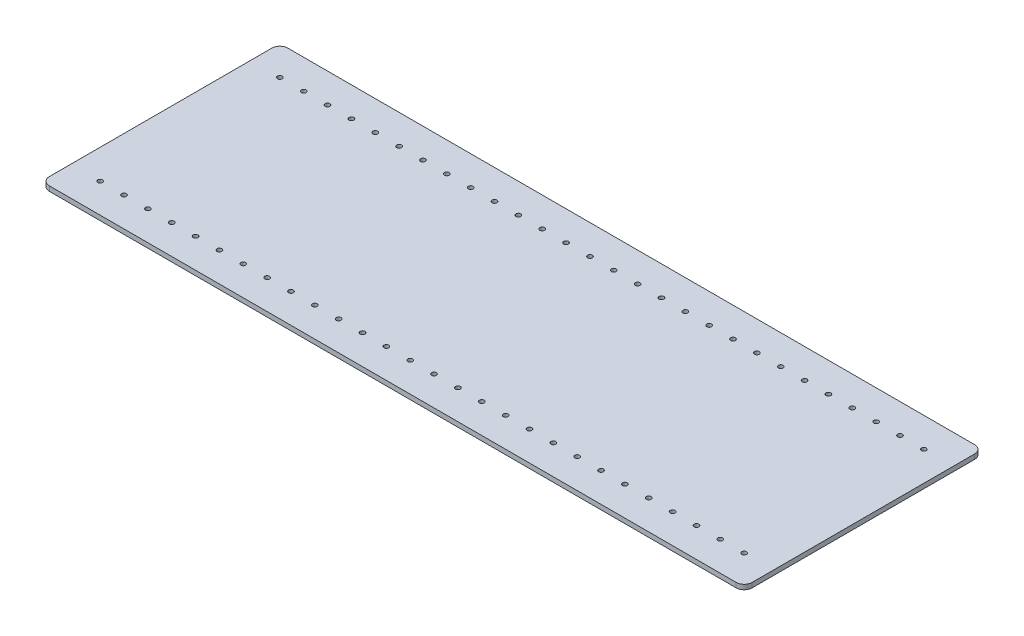
from build123d import *

# Parameters (mm, degrees)
SKETCH2_R           = 1.5
BOSS_EXTRUDE1_DEPTH = 3


with BuildPart() as part:
    # Sketch2 → Boss-Extrude1 (new body)
    with BuildSketch(Plane(origin=(0, 0, 0), x_dir=(1, 0, 0), z_dir=(0, 1, 0))):
        with BuildLine():
            Line((0, 5), (0, 145))
            ThreePointArc((0, 145), (1.464466094, 148.535533906), (5, 150))
            Line((5, 150), (437, 150))
            ThreePointArc((437, 150), (440.535533906, 148.535533906), (442, 145))
            Line((442, 145), (442, 5))
            ThreePointArc((442, 5), (440.535533906, 1.464466094), (437, 0))
            Line((437, 0), (5, 0))
            ThreePointArc((5, 0), (1.464466094, 1.464466094), (0, 5))
        make_face()
        with Locations((18.5, 131.5)):
            Circle(SKETCH2_R, mode=Mode.SUBTRACT)
        with Locations((18.5, 18.5)):
            Circle(SKETCH2_R, mode=Mode.SUBTRACT)
        with Locations((78.5, 18.5)):
            Circle(SKETCH2_R, mode=Mode.SUBTRACT)
        with Locations((63.5, 18.5)):
            Circle(SKETCH2_R, mode=Mode.SUBTRACT)
        with Locations((48.5, 18.5)):
            Circle(SKETCH2_R, mode=Mode.SUBTRACT)
        with Locations((33.5, 18.5)):
            Circle(SKETCH2_R, mode=Mode.SUBTRACT)
        with Locations((78.5, 131.5)):
            Circle(SKETCH2_R, mode=Mode.SUBTRACT)
        with Locations((63.5, 131.5)):
            Circle(SKETCH2_R, mode=Mode.SUBTRACT)
        with Locations((48.5, 131.5)):
            Circle(SKETCH2_R, mode=Mode.SUBTRACT)
        with Locations((33.5, 131.5)):
            Circle(SKETCH2_R, mode=Mode.SUBTRACT)
        with Locations((123.5, 131.5)):
            Circle(SKETCH2_R, mode=Mode.SUBTRACT)
        with Locations((108.5, 131.5)):
            Circle(SKETCH2_R, mode=Mode.SUBTRACT)
        with Locations((93.5, 131.5)):
            Circle(SKETCH2_R, mode=Mode.SUBTRACT)
        with Locations((123.5, 18.5)):
            Circle(SKETCH2_R, mode=Mode.SUBTRACT)
        with Locations((108.5, 18.5)):
            Circle(SKETCH2_R, mode=Mode.SUBTRACT)
        with Locations((93.5, 18.5)):
            Circle(SKETCH2_R, mode=Mode.SUBTRACT)
        with Locations((138.5, 18.5)):
            Circle(SKETCH2_R, mode=Mode.SUBTRACT)
        with Locations((153.5, 131.5)):
            Circle(SKETCH2_R, mode=Mode.SUBTRACT)
        with Locations((138.5, 131.5)):
            Circle(SKETCH2_R, mode=Mode.SUBTRACT)
        with Locations((183.5, 131.5)):
            Circle(SKETCH2_R, mode=Mode.SUBTRACT)
        with Locations((168.5, 131.5)):
            Circle(SKETCH2_R, mode=Mode.SUBTRACT)
        with Locations((183.5, 18.5)):
            Circle(SKETCH2_R, mode=Mode.SUBTRACT)
        with Locations((168.5, 18.5)):
            Circle(SKETCH2_R, mode=Mode.SUBTRACT)
        with Locations((153.5, 18.5)):
            Circle(SKETCH2_R, mode=Mode.SUBTRACT)
        with Locations((198.5, 18.5)):
            Circle(SKETCH2_R, mode=Mode.SUBTRACT)
        with Locations((243.5, 18.5)):
            Circle(SKETCH2_R, mode=Mode.SUBTRACT)
        with Locations((228.5, 18.5)):
            Circle(SKETCH2_R, mode=Mode.SUBTRACT)
        with Locations((213.5, 18.5)):
            Circle(SKETCH2_R, mode=Mode.SUBTRACT)
        with Locations((258.5, 18.5)):
            Circle(SKETCH2_R, mode=Mode.SUBTRACT)
        with Locations((303.5, 18.5)):
            Circle(SKETCH2_R, mode=Mode.SUBTRACT)
        with Locations((288.5, 18.5)):
            Circle(SKETCH2_R, mode=Mode.SUBTRACT)
        with Locations((273.5, 18.5)):
            Circle(SKETCH2_R, mode=Mode.SUBTRACT)
        with Locations((333.5, 18.5)):
            Circle(SKETCH2_R, mode=Mode.SUBTRACT)
        with Locations((318.5, 18.5)):
            Circle(SKETCH2_R, mode=Mode.SUBTRACT)
        with Locations((348.5, 18.5)):
            Circle(SKETCH2_R, mode=Mode.SUBTRACT)
        with Locations((393.5, 18.5)):
            Circle(SKETCH2_R, mode=Mode.SUBTRACT)
        with Locations((378.5, 18.5)):
            Circle(SKETCH2_R, mode=Mode.SUBTRACT)
        with Locations((363.5, 18.5)):
            Circle(SKETCH2_R, mode=Mode.SUBTRACT)
        with Locations((423.5, 18.5)):
            Circle(SKETCH2_R, mode=Mode.SUBTRACT)
        with Locations((408.5, 18.5)):
            Circle(SKETCH2_R, mode=Mode.SUBTRACT)
        with Locations((198.5, 131.5)):
            Circle(SKETCH2_R, mode=Mode.SUBTRACT)
        with Locations((228.5, 131.5)):
            Circle(SKETCH2_R, mode=Mode.SUBTRACT)
        with Locations((213.5, 131.5)):
            Circle(SKETCH2_R, mode=Mode.SUBTRACT)
        with Locations((258.5, 131.5)):
            Circle(SKETCH2_R, mode=Mode.SUBTRACT)
        with Locations((243.5, 131.5)):
            Circle(SKETCH2_R, mode=Mode.SUBTRACT)
        with Locations((288.5, 131.5)):
            Circle(SKETCH2_R, mode=Mode.SUBTRACT)
        with Locations((273.5, 131.5)):
            Circle(SKETCH2_R, mode=Mode.SUBTRACT)
        with Locations((318.5, 131.5)):
            Circle(SKETCH2_R, mode=Mode.SUBTRACT)
        with Locations((303.5, 131.5)):
            Circle(SKETCH2_R, mode=Mode.SUBTRACT)
        with Locations((348.5, 131.5)):
            Circle(SKETCH2_R, mode=Mode.SUBTRACT)
        with Locations((333.5, 131.5)):
            Circle(SKETCH2_R, mode=Mode.SUBTRACT)
        with Locations((378.5, 131.5)):
            Circle(SKETCH2_R, mode=Mode.SUBTRACT)
        with Locations((363.5, 131.5)):
            Circle(SKETCH2_R, mode=Mode.SUBTRACT)
        with Locations((423.5, 131.5)):
            Circle(SKETCH2_R, mode=Mode.SUBTRACT)
        with Locations((408.5, 131.5)):
            Circle(SKETCH2_R, mode=Mode.SUBTRACT)
        with Locations((393.5, 131.5)):
            Circle(SKETCH2_R, mode=Mode.SUBTRACT)
    extrude(amount=BOSS_EXTRUDE1_DEPTH)


solid = part.part
